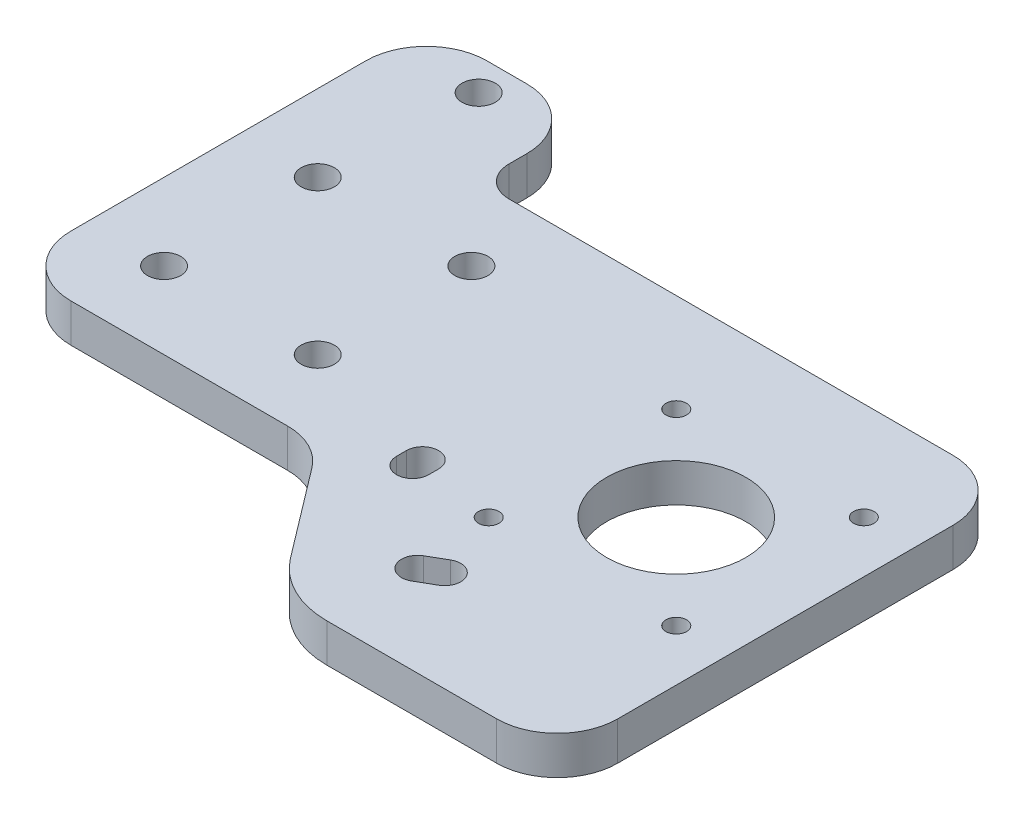
from build123d import *

# Parameters (mm, degrees)
BOSS_EXTRUDE1_DEPTH  = 6.35
M5_CLEARANCE_HOLE1_D = 5.5
CUT_EXTRUDE2_DEPTH   = 7.35
FILLET1_R            = 10
M3_CLEARANCE_HOLE1_D = 3.4
SKETCH10_R           = 11.5
CUT_EXTRUDE3_DEPTH   = 7.35
FILLET2_R            = 5


with BuildPart() as part:
    # Sketch1 → Boss-Extrude1 (new body)
    with BuildSketch(Plane(origin=(0, 0, 0), x_dir=(1, 0, 0), z_dir=(0, 1, 0))):
        with BuildLine():
            Line((25.4, -25.4), (-25.4, -25.4))
            Line((-25.4, -25.4), (-25.4, 25.4))
            Line((-25.4, 25.4), (-25.4, 43.35))
            Line((-25.4, 43.35), (1.2, 43.35))
            Line((1.2, 43.35), (1.2, 25.4))
            Line((1.2, 25.4), (25.4, 25.4))
            Line((25.4, 25.4), (89.621209859, 25.4))
            Line((89.621209859, 25.4), (89.621209859, -50.04))
            Line((89.621209859, -50.04), (51.541941751, -50.04))
            ThreePointArc((51.541941751, -50.04), (44.870841587, -48.474895705), (39.591870426, -44.10618968))
            Line((39.591870426, -44.10618968), (25.4, -25.4))
        make_face()
    extrude(amount=BOSS_EXTRUDE1_DEPTH)

    # M5 Clearance Hole1 (through all)
    with Locations(Plane(origin=(0, 6.35, 0), x_dir=(1, 0, 0), z_dir=(0, 1, 0))):
        with Locations((-12.7, 12.7), (12.7, 12.7), (12.7, -12.7), (-12.7, -12.7), (-11.5, 38.1)):
            Hole(M5_CLEARANCE_HOLE1_D / 2)

    # Sketch7 → Cut-Extrude2 (cut, through all)
    with BuildSketch(Plane(origin=(0, 6.35, 0), x_dir=(1, 0, 0), z_dir=(0, 1, 0))):
        with BuildLine():
            Line((53.051764766, -31.105892862), (50.215452987, -32.745892862))
            ThreePointArc((50.215452987, -32.745892862), (49.247834614, -36.366488764), (52.868430515, -37.334107138))
            Line((52.868430515, -37.334107138), (55.704742294, -35.694107138))
            ThreePointArc((55.704742294, -35.694107138), (56.672360668, -32.073511236), (53.051764766, -31.105892862))
        make_face()
        with BuildLine():
            Line((33.75, -19.08), (33.75, -20.72))
            ThreePointArc((33.75, -20.72), (36.4, -23.37), (39.05, -20.72))
            Line((39.05, -20.72), (39.05, -19.08))
            ThreePointArc((39.05, -19.08), (36.4, -16.43), (33.75, -19.08))
        make_face()
    extrude(amount=-CUT_EXTRUDE2_DEPTH, mode=Mode.SUBTRACT)

    # Fillet1
    fillet1_edges = [part.edges().sort_by_distance(p)[0] for p in [
        (-25.4, 3.175, -43.35),
        (1.2, 3.175, -43.35),
        (89.621209859, 3.175, -25.4),
        (89.621209859, 3.175, 50.04),
        (25.4, 3.175, 25.4),
        (-25.4, 3.175, 25.4),
    ]]
    fillet(fillet1_edges, radius=FILLET1_R)

    # M3 Clearance Hole1 (through all)
    with Locations(Plane(origin=(0, 6.35, 0), x_dir=(1, 0, 0), z_dir=(0, 1, 0))):
        with Locations((50.121209859, 9.14), (81.121209859, 9.14), (81.121209859, -21.86), (50.121209859, -21.86)):
            Hole(M3_CLEARANCE_HOLE1_D / 2)

    # Sketch10 → Cut-Extrude3 (cut, through all)
    with BuildSketch(Plane(origin=(0, 6.35, 0), x_dir=(1, 0, 0), z_dir=(0, 1, 0))):
        with Locations((65.621209859, -6.36)):
            Circle(SKETCH10_R)
    extrude(amount=-CUT_EXTRUDE3_DEPTH, mode=Mode.SUBTRACT)

    # Fillet2
    fillet2_edges = [part.edges().sort_by_distance(p)[0] for p in [
        (1.2, 3.175, -25.4),
    ]]
    fillet(fillet2_edges, radius=FILLET2_R)


solid = part.part
